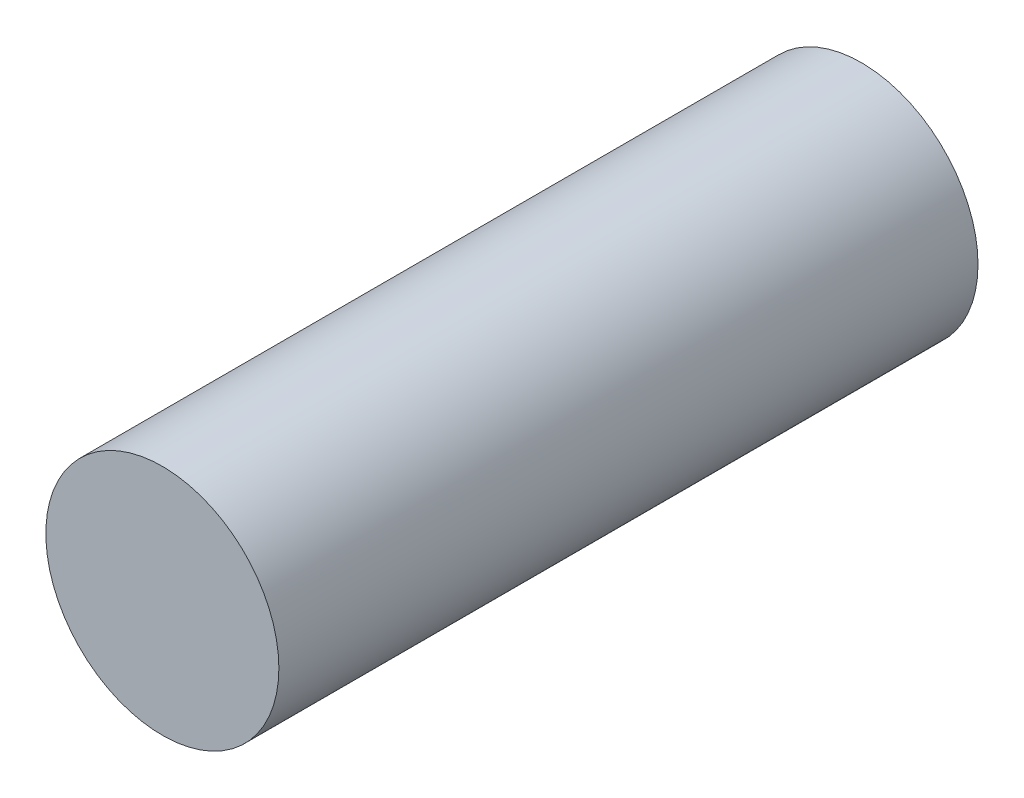
from build123d import *

# Parameters (mm, degrees)
SKETCH1_R           = 3
BOSS_EXTRUDE1_DEPTH = 18


with BuildPart() as part:
    # Sketch1 → Boss-Extrude1 (new body)
    with BuildSketch(Plane.XY):
        Circle(SKETCH1_R)
    extrude(amount=BOSS_EXTRUDE1_DEPTH)


solid = part.part
